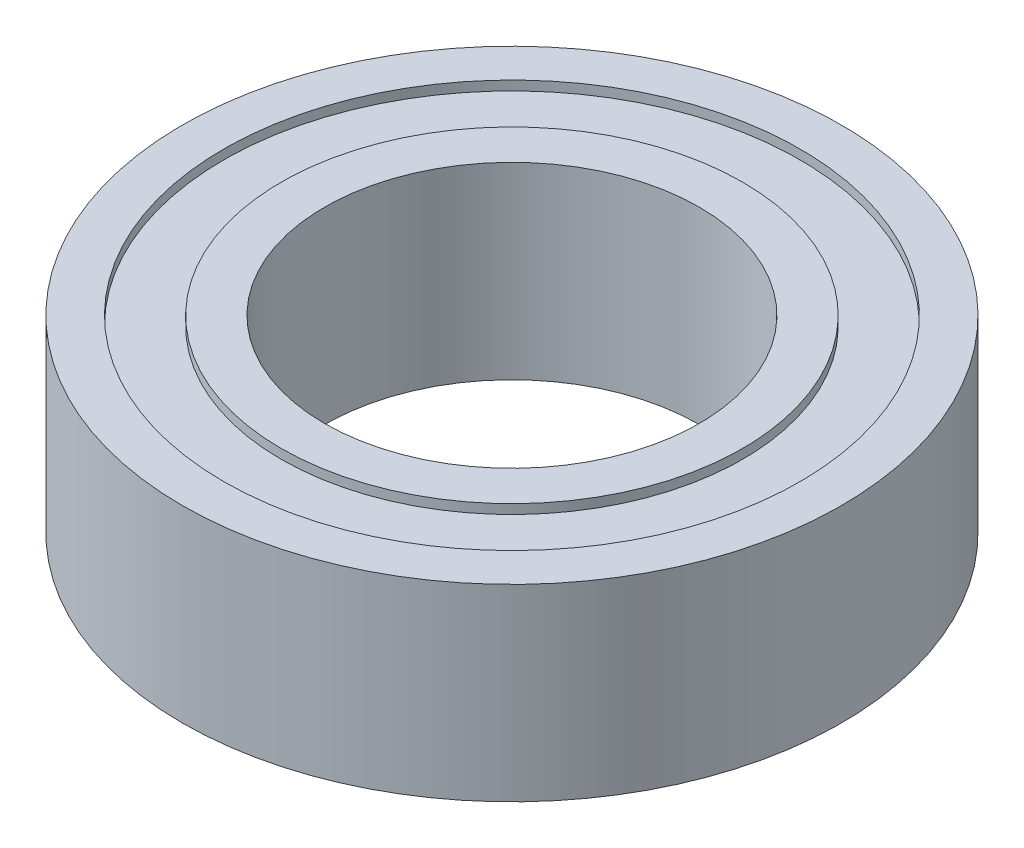
from build123d import *

# Parameters (mm, degrees)
SKETCH1_R               = 7
BOSS_EXTRUDE1_DEPTH     = 2
SKETCH2_R               = 3.98
CUT_EXTRUDE1_DEPTH      = 3
CUT_EXTRUDE1_DEPTH_BACK = 3
CUT_EXTRUDE2_START      = 2
SKETCH3_R               = 6.12
SKETCH3_R_2             = 4.9
CUT_EXTRUDE2_DEPTH      = 0.2


with BuildPart() as part:
    # Sketch1 → Boss-Extrude1 (new body, symmetric)
    with BuildSketch(Plane(origin=(0, 0, 0), x_dir=(1, 0, 0), z_dir=(0, 1, 0))):
        Circle(SKETCH1_R)
    extrude(amount=BOSS_EXTRUDE1_DEPTH, both=True)

    # Sketch2 → Cut-Extrude1 (cut, two sides)
    with BuildSketch(Plane(origin=(0, 0, 0), x_dir=(1, 0, 0), z_dir=(0, 1, 0))) as cut_extrude1_sk:
        Circle(SKETCH2_R)
    extrude(amount=CUT_EXTRUDE1_DEPTH, mode=Mode.SUBTRACT)
    extrude(cut_extrude1_sk.sketch, amount=-CUT_EXTRUDE1_DEPTH_BACK, mode=Mode.SUBTRACT)

    # Sketch3 → Cut-Extrude2 (cut)
    with BuildSketch(Plane(origin=(0, 0, 0), x_dir=(1, 0, 0), z_dir=(0, 1, 0)).offset(CUT_EXTRUDE2_START)):
        Circle(SKETCH3_R)
        Circle(SKETCH3_R_2, mode=Mode.SUBTRACT)
    cut_extrude2 = extrude(amount=-CUT_EXTRUDE2_DEPTH, mode=Mode.SUBTRACT)

    # Mirror1: Cut-Extrude2 across plane
    add(cut_extrude2.mirror(Plane.ZX), mode=Mode.SUBTRACT)


solid = part.part
